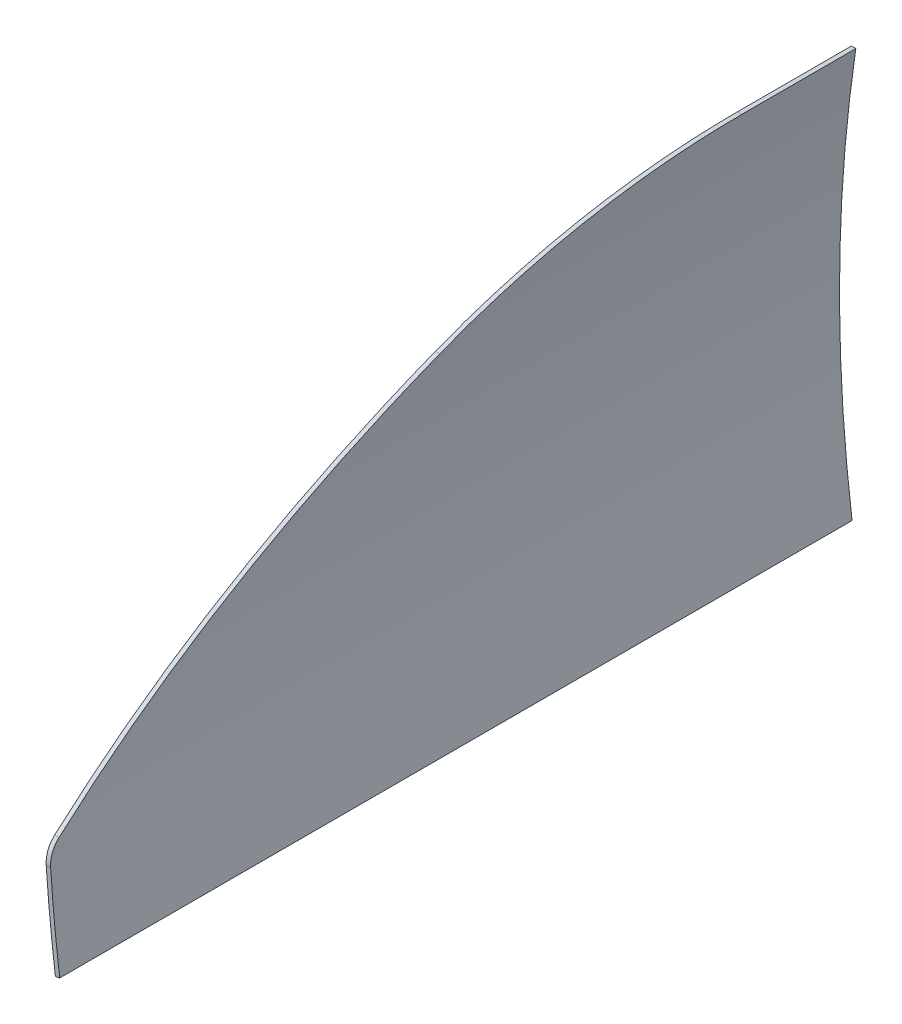
from build123d import *

# Parameters (mm, degrees)
EXTRUDE_THIN1_DEPTH = 500
SKETCH2_OUTSIDE_W   = 1225.724
SKETCH2_OUTSIDE_H   = 726.468
CUT_EXTRUDE1_DEPTH  = 40
CUT_EXTRUDE2_DEPTH  = 905.0000001


with BuildPart() as part:
    # Sketch1 → Extrude-Thin1 (new body, symmetric)
    with BuildSketch(Plane.XY):
        with BuildLine():
            ThreePointArc((2.472217938, 0.371669838), (-16.187326406, 250), (2.472217938, 499.628330162))
            Line((2.472217938, 499.628330162), (-2.472217938, 500.371669838))
            ThreePointArc((-2.472217938, 500.371669838), (-21.187326406, 250), (-2.472217938, -0.371669838))
            Line((-2.472217938, -0.371669838), (2.472217938, 0.371669838))
        make_face()
    extrude(amount=EXTRUDE_THIN1_DEPTH, both=True)

    # Sketch2 outside → Cut-Extrude1 (cut, symmetric)
    with BuildSketch(Plane(origin=(0, 0, 0), x_dir=(0, 0, -1), z_dir=(1, 0, 0))):
        with Locations((0, 250)):
            Rectangle(SKETCH2_OUTSIDE_W, SKETCH2_OUTSIDE_H)
        with BuildLine():
            Line((500, 499.628330162), (370, 499.628330162))
            ThreePointArc((370, 499.628330162), (198.298251655, 480.98516901), (34.59916172, 425.9246042))
            ThreePointArc((34.59916172, 425.9246042), (-187.662872816, 305.701379942), (-392.991389707, 158.411747589))
            ThreePointArc((-392.991389707, 158.411747589), (-401.108501353, 148.038589085), (-404, 135.188330162))
            Line((-404, 135.188330162), (-404, 30.188330162))
            Line((-404, 30.188330162), (500, 30.188330162))
            Line((500, 30.188330162), (500, 499.628330162))
        make_face(mode=Mode.SUBTRACT)
    extrude(amount=CUT_EXTRUDE1_DEPTH, both=True, mode=Mode.SUBTRACT)

    # Sketch3 → Cut-Extrude2 (cut, through all)
    with BuildSketch(Plane.XY.offset(404)):
        Polygon((-6.780603569, 30.188330162), (-1.858216297, 31.105746602), (-1.737331603, 30.188330162), align=None)
    extrude(amount=-CUT_EXTRUDE2_DEPTH, mode=Mode.SUBTRACT)


solid = part.part
